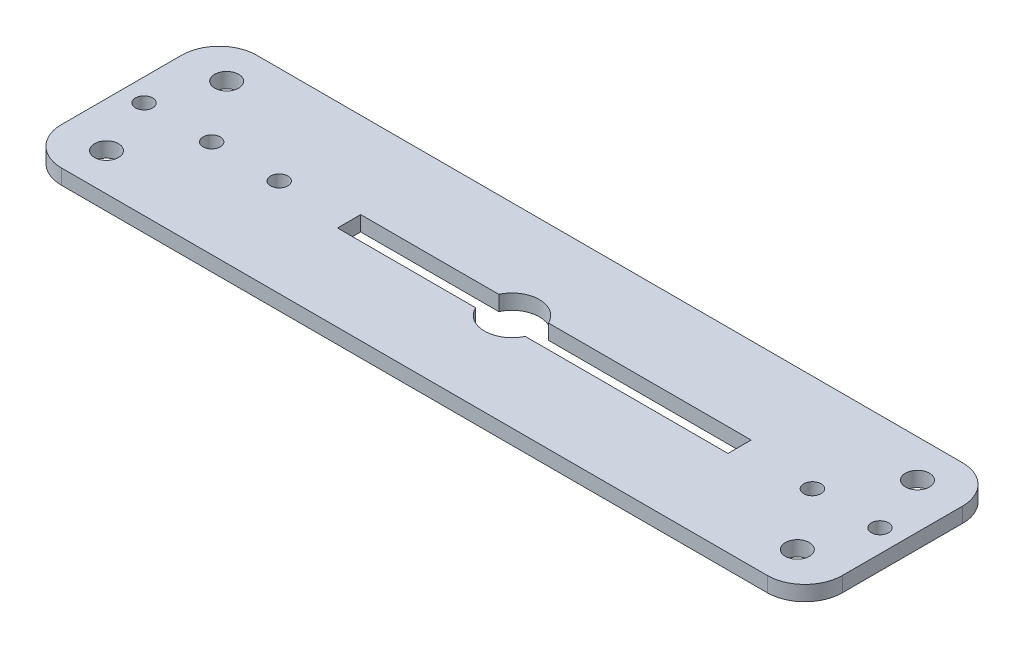
from build123d import *

# Parameters (mm, degrees)
ESBO_O1_R                = 1.6
ESBO_O1_R_2              = 1.15
RESSALTO_EXTRUS_O1_DEPTH = 2


with BuildPart() as part:
    # Esboço1 → Ressalto-extrusão1 (new body)
    with BuildSketch(Plane(origin=(0, 0, 0), x_dir=(1, 0, 0), z_dir=(0, 1, 0))):
        with BuildLine():
            Line((-47, -13), (47, -13))
            ThreePointArc((47, -13), (50.535533906, -11.535533906), (52, -8))
            Line((52, -8), (52, 8))
            ThreePointArc((52, 8), (50.535533906, 11.535533906), (47, 13))
            Line((47, 13), (-47, 13))
            ThreePointArc((-47, 13), (-50.535533906, 11.535533906), (-52, 8))
            Line((-52, 8), (-52, -8))
            ThreePointArc((-52, -8), (-50.535533906, -11.535533906), (-47, -13))
        make_face()
        with Locations((46, 8)):
            Circle(ESBO_O1_R, mode=Mode.SUBTRACT)
        with Locations((46, -8)):
            Circle(ESBO_O1_R, mode=Mode.SUBTRACT)
        with Locations((49, 0)):
            Circle(ESBO_O1_R_2, mode=Mode.SUBTRACT)
        with Locations((40, 0)):
            Circle(ESBO_O1_R_2, mode=Mode.SUBTRACT)
        with Locations((-46, 8)):
            Circle(ESBO_O1_R, mode=Mode.SUBTRACT)
        with Locations((-46, -8)):
            Circle(ESBO_O1_R, mode=Mode.SUBTRACT)
        with Locations((-40, 0)):
            Circle(ESBO_O1_R_2, mode=Mode.SUBTRACT)
        with Locations((-49, 0)):
            Circle(ESBO_O1_R_2, mode=Mode.SUBTRACT)
        with Locations((-31, 0)):
            Circle(ESBO_O1_R_2, mode=Mode.SUBTRACT)
        with BuildLine():
            Line((3.307143995, -1.544441193), (30.307143995, -1.544441193))
            Line((30.307143995, -1.544441193), (30.307143995, 1.544441193))
            Line((30.307143995, 1.544441193), (3.307143995, 1.544441193))
            ThreePointArc((3.307143995, 1.544441193), (0, 3.65), (-3.307143995, 1.544441193))
            Line((-3.307143995, 1.544441193), (-21.692856005, 1.544441193))
            Line((-21.692856005, 1.544441193), (-21.692856005, -1.544441193))
            Line((-21.692856005, -1.544441193), (-3.307143995, -1.544441193))
            ThreePointArc((-3.307143995, -1.544441193), (0, -3.65), (3.307143995, -1.544441193))
        make_face(mode=Mode.SUBTRACT)
    extrude(amount=RESSALTO_EXTRUS_O1_DEPTH)


solid = part.part
